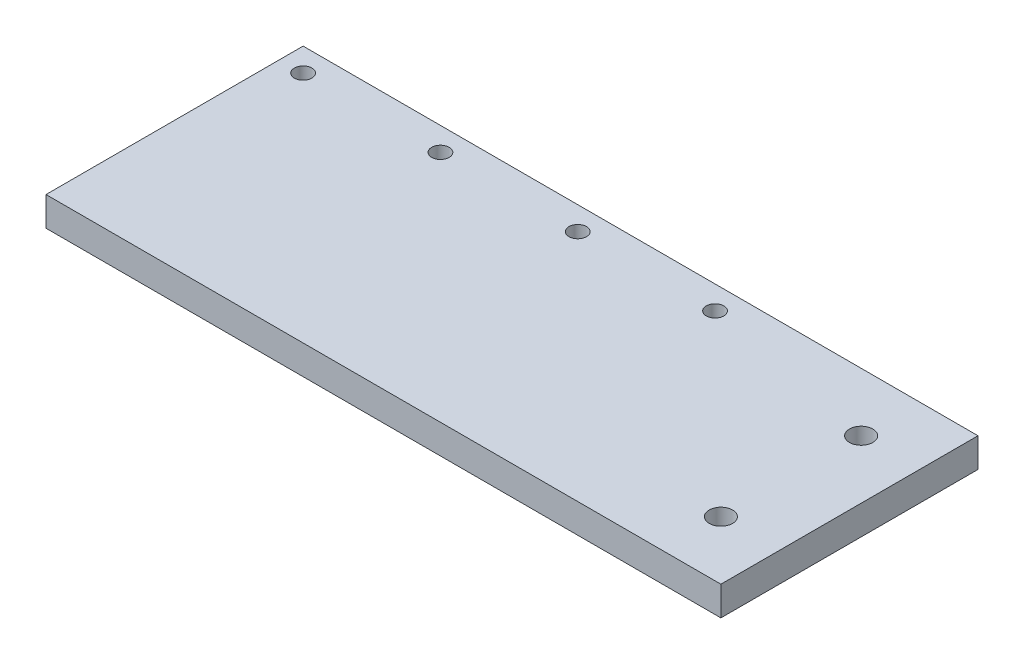
from build123d import *

# Parameters (mm, degrees)
SKETCH1_W           = 95.5
SKETCH1_H           = 44
BOSS_EXTRUDE1_DEPTH = 5
SKETCH2_R           = 1.5
CUT_EXTRUDE1_DEPTH  = 6
SKETCH3_W           = 20
SKETCH3_H           = 44
SKETCH3_R           = 2
BOSS_EXTRUDE2_DEPTH = 5


with BuildPart() as part:
    # Sketch1 → Boss-Extrude1 (new body)
    with BuildSketch(Plane(origin=(0, 0, 0), x_dir=(1, 0, 0), z_dir=(0, 1, 0))):
        Rectangle(SKETCH1_W, SKETCH1_H)
    extrude(amount=BOSS_EXTRUDE1_DEPTH)

    # Sketch2 → Cut-Extrude1 (cut, through all)
    with BuildSketch(Plane(origin=(0, 5, 0), x_dir=(1, 0, 0), z_dir=(0, 1, 0))):
        with Locations((-43.75, 18)):
            Circle(SKETCH2_R)
        with Locations((-20.25, 18)):
            Circle(SKETCH2_R)
        with Locations((3.25, 18)):
            Circle(SKETCH2_R)
        with Locations((26.75, 18)):
            Circle(SKETCH2_R)
    extrude(amount=-CUT_EXTRUDE1_DEPTH, mode=Mode.SUBTRACT)

    # Sketch3 → Boss-Extrude2 (add)
    with BuildSketch(Plane(origin=(0, 5, 0), x_dir=(1, 0, 0), z_dir=(0, 1, 0))):
        with Locations((57.75, 0)):
            Rectangle(SKETCH3_W, SKETCH3_H)
        with Locations((57.75, 12)):
            Circle(SKETCH3_R, mode=Mode.SUBTRACT)
        with Locations((57.75, -12)):
            Circle(SKETCH3_R, mode=Mode.SUBTRACT)
    extrude(amount=-BOSS_EXTRUDE2_DEPTH)


solid = part.part
